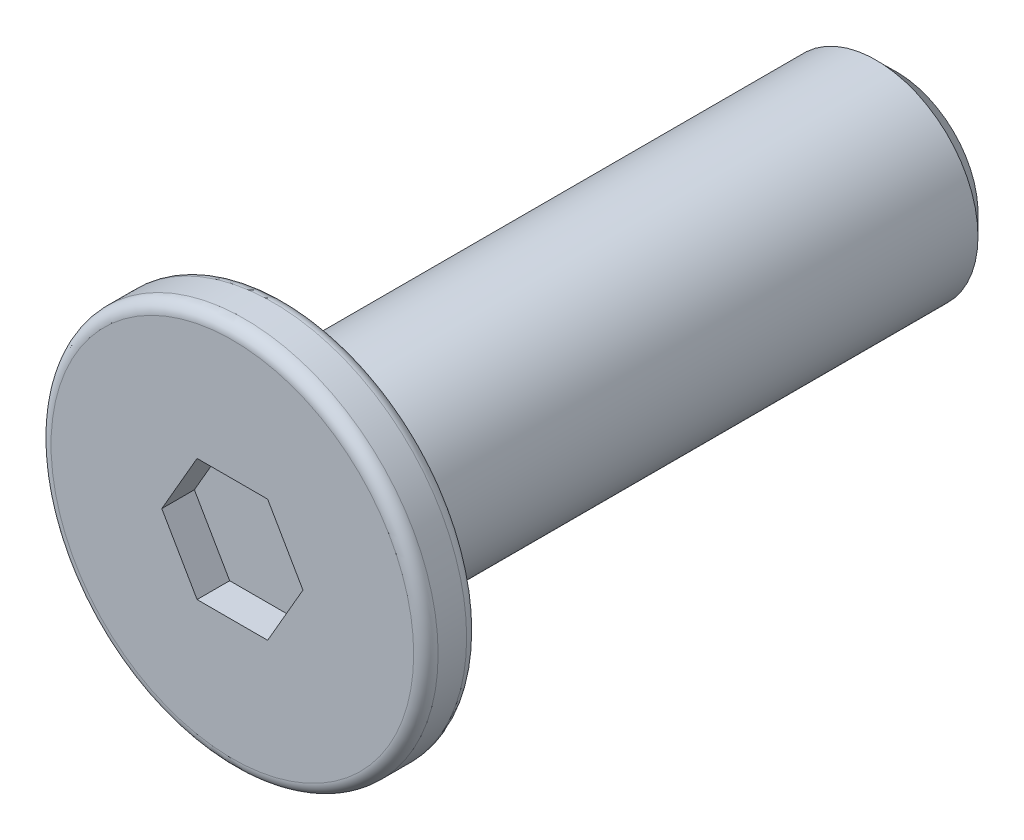
from build123d import *

# Parameters (mm, degrees)
SKETCH_1_R          = 4.75
EXTRUDE_1_DEPTH     = 0.65
SKETCH_2_R          = 2.5
EXTRUDE_2_DEPTH     = 15
CHAMFER_1_SIZE      = 0.5
CUT_EXTRUDE_1_DEPTH = 0.8
FILLET_2_R          = 0.3


with BuildPart() as part:
    # 草图1 → 凸台-拉伸1 (new body, symmetric)
    with BuildSketch(Plane.XY):
        Circle(SKETCH_1_R)
    extrude(amount=EXTRUDE_1_DEPTH, both=True)

    # 草图2 → 凸台-拉伸2 (add)
    with BuildSketch(Plane(origin=(0, 0, -0.65), x_dir=(-1, 0, 0), z_dir=(0, 0, -1))):
        Circle(SKETCH_2_R)
    extrude(amount=EXTRUDE_2_DEPTH)

    # 倒角1
    chamfer_1_edges = [part.edges().sort_by_distance(p)[0] for p in [
        (2.5, 0, -15.65),
    ]]
    chamfer(chamfer_1_edges, length=CHAMFER_1_SIZE)

    # 草图3 → 切除-拉伸1 (cut)
    with BuildSketch(Plane.XY.offset(0.65)):
        Polygon((1.732050808, 0), (0.866025404, 1.5), (-0.866025404, 1.5), (-1.732050808, 0), (-0.866025404, -1.5), (0.866025404, -1.5), align=None)
    extrude(amount=-CUT_EXTRUDE_1_DEPTH, mode=Mode.SUBTRACT)

    # 圆角2
    fillet_2_edges = [part.edges().sort_by_distance(p)[0] for p in [
        (-4.75, 0, -0.65),
        (-4.75, 0, 0.65),
    ]]
    fillet(fillet_2_edges, radius=FILLET_2_R)


solid = part.part
